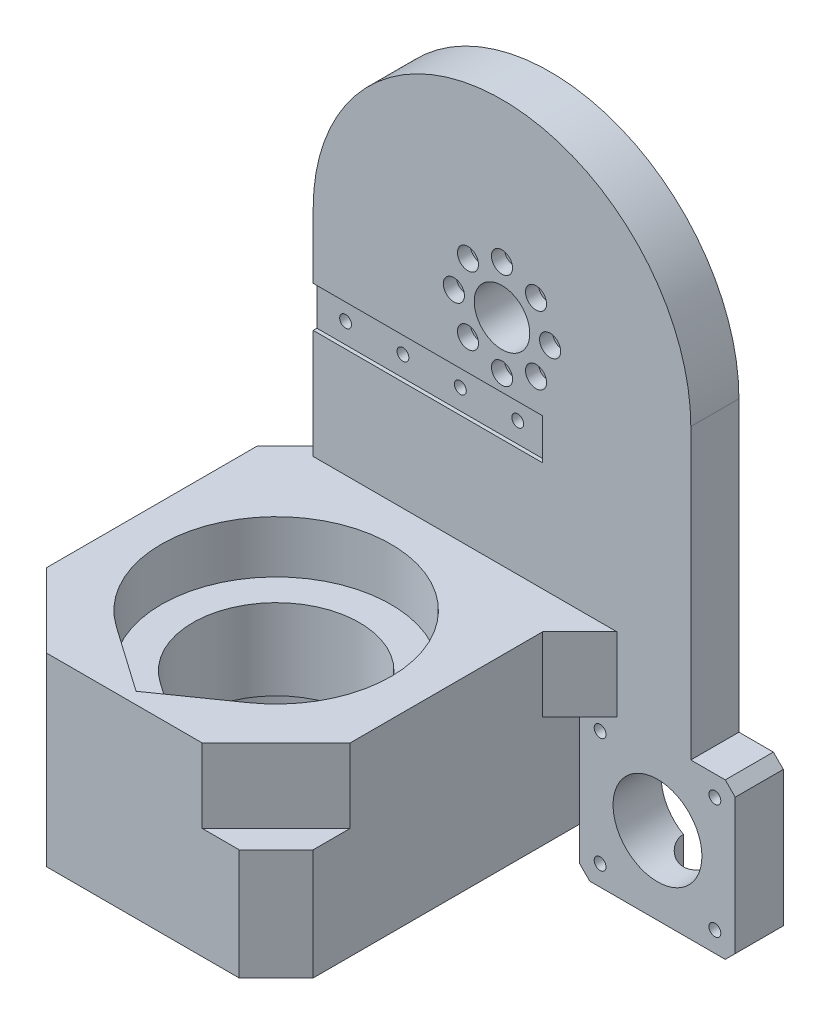
from build123d import *

# Parameters (mm, degrees)
SKETCH1_R               = 12
SKETCH1_R_2             = 7.5
SKETCH1_R_3             = 1.6
BOSS_EXTRUDE2_DEPTH     = 13
SKETCH1_6_W             = 50
SKETCH1_6_H             = 82
BOSS_EXTRUDE3_DEPTH     = 82
SKETCH1_5_R             = 2.85
CUT_EXTRUDE2_DEPTH      = 3.5
CUT_EXTRUDE3_DEPTH      = 14.1
CUT_EXTRUDE4_START      = -50
CUT_EXTRUDE4_DEPTH      = 14.1
CUT_EXTRUDE5_DEPTH      = 110
CUT_EXTRUDE5_DEPTH_BACK = 63
SKETCH3_W               = 62
SKETCH3_H               = 11
CUT_EXTRUDE6_DEPTH      = 1
SKETCH3_3_R             = 1.6
CUT_EXTRUDE7_DEPTH      = 14
CUT_EXTRUDE8_START      = -13
SKETCH3_5_R             = 2.85
CUT_EXTRUDE8_DEPTH      = 3.5
CUT_EXTRUDE9_START      = -13
SKETCH1_7_R             = 2.85
CUT_EXTRUDE9_DEPTH      = 3.5
CUT_EXTRUDE10_DEPTH     = 12.5
BOSS_EXTRUDE4_DEPTH     = 50
CUT_EXTRUDE11_DEPTH     = 50.5
BOSS_EXTRUDE5_DEPTH     = 20
CUT_EXTRUDE12_DEPTH     = 20
CHAMFER6_SIZE           = 10


with BuildPart() as part:
    # Sketch1 → Boss-Extrude2 (new body)
    with BuildSketch(Plane(origin=(0, 0, 0), x_dir=(0, 1, 0), z_dir=(0, 0, 1))):
        with BuildLine():
            Line((-68, -41), (-77.30151519, -41))
            Line((-77.30151519, -41), (-80, -43.69848481))
            Line((-80, -43.69848481), (-80, -80.30151519))
            Line((-80, -80.30151519), (-77.30151519, -83))
            Line((-77.30151519, -83), (-40.69848481, -83))
            Line((-40.69848481, -83), (-38, -80.30151519))
            Line((-38, -80.30151519), (-38, -71))
            Line((-38, -71), (40, -71))
            ThreePointArc((40, -71), (91, -20), (40, 31))
            Line((40, 31), (-68, 31))
            Line((-68, 31), (-68, -41))
        make_face()
        with Locations((-59, -62)):
            Circle(SKETCH1_R, mode=Mode.SUBTRACT)
        with Locations((40, -20)):
            Circle(SKETCH1_R_2, mode=Mode.SUBTRACT)
        with Locations((40, -7)):
            Circle(SKETCH1_R_3, mode=Mode.SUBTRACT)
        with Locations((49.192388155, -10.807611845)):
            Circle(SKETCH1_R_3, mode=Mode.SUBTRACT)
        with Locations((53, -20)):
            Circle(SKETCH1_R_3, mode=Mode.SUBTRACT)
        with Locations((49.192388155, -29.192388155)):
            Circle(SKETCH1_R_3, mode=Mode.SUBTRACT)
        with Locations((40, -33)):
            Circle(SKETCH1_R_3, mode=Mode.SUBTRACT)
        with Locations((30.807611845, -29.192388155)):
            Circle(SKETCH1_R_3, mode=Mode.SUBTRACT)
        with Locations((27, -20)):
            Circle(SKETCH1_R_3, mode=Mode.SUBTRACT)
        with Locations((30.807611845, -10.807611845)):
            Circle(SKETCH1_R_3, mode=Mode.SUBTRACT)
        with Locations((-74.5, -46.5)):
            Circle(SKETCH1_R_3, mode=Mode.SUBTRACT)
        with Locations((-43.5, -46.5)):
            Circle(SKETCH1_R_3, mode=Mode.SUBTRACT)
        with Locations((-43.5, -77.5)):
            Circle(SKETCH1_R_3, mode=Mode.SUBTRACT)
        with Locations((-74.5, -77.5)):
            Circle(SKETCH1_R_3, mode=Mode.SUBTRACT)
    extrude(amount=-BOSS_EXTRUDE2_DEPTH)

    # Sketch1_6 → Boss-Extrude3 (add)
    with BuildSketch(Plane(origin=(0, 0, 0), x_dir=(0, 1, 0), z_dir=(0, 0, 1))):
        with Locations((-43, 0)):
            Rectangle(SKETCH1_6_W, SKETCH1_6_H)
    extrude(amount=BOSS_EXTRUDE3_DEPTH)

    # Sketch1_5 → Cut-Extrude2 (cut)
    with BuildSketch(Plane(origin=(0, 0, 0), x_dir=(0, 1, 0), z_dir=(0, 0, 1))):
        with Locations((40, -7)):
            Circle(SKETCH1_5_R)
        with Locations((49.192388155, -10.807611845)):
            Circle(SKETCH1_5_R)
        with Locations((53, -20)):
            Circle(SKETCH1_5_R)
        with Locations((49.192388155, -29.192388155)):
            Circle(SKETCH1_5_R)
        with Locations((40, -33)):
            Circle(SKETCH1_5_R)
        with Locations((30.807611845, -29.192388155)):
            Circle(SKETCH1_5_R)
        with Locations((27, -20)):
            Circle(SKETCH1_5_R)
        with Locations((30.807611845, -10.807611845)):
            Circle(SKETCH1_5_R)
    extrude(amount=-CUT_EXTRUDE2_DEPTH, mode=Mode.SUBTRACT)

    # Sketch2 → Cut-Extrude3 (cut)
    with BuildSketch(Plane(origin=(0, -18, 0), x_dir=(-1, 0, 0), z_dir=(0, 1, 0))):
        with BuildLine():
            Line((-17.780869527, 66.393713373), (0, 78.844012252))
            Line((0, 78.844012252), (17.780869527, 66.393713373))
            ThreePointArc((17.780869527, 66.393713373), (0, 10), (-17.780869527, 66.393713373))
        make_face()
    extrude(amount=-CUT_EXTRUDE3_DEPTH, mode=Mode.SUBTRACT)

    # Sketch2_3 → Cut-Extrude4 (cut)
    with BuildSketch(Plane(origin=(0, -18, 0), x_dir=(-1, 0, 0), z_dir=(0, 1, 0)).offset(CUT_EXTRUDE4_START)):
        with BuildLine():
            Line((-17.780869527, 66.393713373), (0, 78.844012252))
            Line((0, 78.844012252), (17.780869527, 66.393713373))
            ThreePointArc((17.780869527, 66.393713373), (0, 10), (-17.780869527, 66.393713373))
        make_face()
        with BuildLine():
            Line((-12.905469818, 59.430920997), (0, 68.467428247))
            Line((0, 68.467428247), (12.905469818, 59.430920997))
            ThreePointArc((12.905469818, 59.430920997), (0, 18.5), (-12.905469818, 59.430920997))
        make_face(mode=Mode.SUBTRACT)
    extrude(amount=CUT_EXTRUDE4_DEPTH, mode=Mode.SUBTRACT)

    # Sketch2_4 → Cut-Extrude5 (cut, two sides)
    with BuildSketch(Plane(origin=(0, -18, 0), x_dir=(-1, 0, 0), z_dir=(0, 1, 0))) as cut_extrude5_sk:
        with BuildLine():
            Line((-12.905469818, 59.430920997), (0, 68.467428247))
            Line((0, 68.467428247), (12.905469818, 59.430920997))
            ThreePointArc((12.905469818, 59.430920997), (0, 18.5), (-12.905469818, 59.430920997))
        make_face()
    extrude(amount=CUT_EXTRUDE5_DEPTH, mode=Mode.SUBTRACT)
    extrude(cut_extrude5_sk.sketch, amount=-CUT_EXTRUDE5_DEPTH_BACK, mode=Mode.SUBTRACT)

    # Sketch3 → Cut-Extrude6 (cut)
    with BuildSketch(Plane.XY):
        with Locations((0, 17)):
            Rectangle(SKETCH3_W, SKETCH3_H)
    extrude(amount=-CUT_EXTRUDE6_DEPTH, mode=Mode.SUBTRACT)

    # Sketch3_3 → Cut-Extrude7 (cut, through all)
    with BuildSketch(Plane.XY):
        with Locations((-23.25, 17)):
            Circle(SKETCH3_3_R)
        with Locations((-7.75, 17)):
            Circle(SKETCH3_3_R)
        with Locations((7.75, 17)):
            Circle(SKETCH3_3_R)
        with Locations((23.25, 17)):
            Circle(SKETCH3_3_R)
    extrude(amount=-CUT_EXTRUDE7_DEPTH, mode=Mode.SUBTRACT)

    # Sketch3_5 → Cut-Extrude8 (cut)
    with BuildSketch(Plane.XY.offset(CUT_EXTRUDE8_START)):
        with Locations((-23.25, 17)):
            Circle(SKETCH3_5_R)
        with Locations((-7.75, 17)):
            Circle(SKETCH3_5_R)
        with Locations((7.75, 17)):
            Circle(SKETCH3_5_R)
        with Locations((23.25, 17)):
            Circle(SKETCH3_5_R)
    extrude(amount=CUT_EXTRUDE8_DEPTH, mode=Mode.SUBTRACT)

    # Sketch1_7 → Cut-Extrude9 (cut)
    with BuildSketch(Plane(origin=(0, 0, 0), x_dir=(0, 1, 0), z_dir=(0, 0, 1)).offset(CUT_EXTRUDE9_START)):
        with Locations((-74.5, -46.5)):
            Circle(SKETCH1_7_R)
        with Locations((-43.5, -46.5)):
            Circle(SKETCH1_7_R)
        with Locations((-43.5, -77.5)):
            Circle(SKETCH1_7_R)
        with Locations((-74.5, -77.5)):
            Circle(SKETCH1_7_R)
    extrude(amount=CUT_EXTRUDE9_DEPTH, mode=Mode.SUBTRACT)

    # Sketch4 → Cut-Extrude10 (cut)
    with BuildSketch(Plane.XZ.offset(80)):
        with BuildLine():
            Line((56, -13), (68, -13))
            ThreePointArc((68, -13), (62, -7), (56, -13))
        make_face()
    extrude(amount=-CUT_EXTRUDE10_DEPTH, mode=Mode.SUBTRACT)

    # Sketch5 → Boss-Extrude4 (add)
    with BuildSketch(Plane(origin=(0, -18, 0), x_dir=(-1, 0, 0), z_dir=(0, 1, 0))):
        Polygon((36, 0), (31, 0), (31, -5), align=None)
    extrude(amount=-BOSS_EXTRUDE4_DEPTH)

    # Sketch5_3 → Cut-Extrude11 (cut)
    with BuildSketch(Plane(origin=(0, -18, 0), x_dir=(-1, 0, 0), z_dir=(0, 1, 0))):
        Polygon((21, 82), (41, 62), (41, 82), align=None)
        Polygon((41, 5), (36, 0), (41, 0), align=None)
    extrude(amount=-CUT_EXTRUDE11_DEPTH, mode=Mode.SUBTRACT)

    # Sketch5_4 → Boss-Extrude5 (add)
    with BuildSketch(Plane(origin=(0, -18, 0), x_dir=(-1, 0, 0), z_dir=(0, 1, 0))):
        Polygon((-51, 0), (-41, 10), (-41, 0), align=None)
    extrude(amount=-BOSS_EXTRUDE5_DEPTH)

    # Sketch5_5 → Cut-Extrude12 (cut)
    with BuildSketch(Plane(origin=(0, -18, 0), x_dir=(-1, 0, 0), z_dir=(0, 1, 0))):
        Polygon((-41, 62), (-21, 82), (-41, 82), align=None)
    extrude(amount=-CUT_EXTRUDE12_DEPTH, mode=Mode.SUBTRACT)

    # Chamfer6
    chamfer6_edges = [part.edges().sort_by_distance(p)[0] for p in [
        (41, -53, 82),
    ]]
    chamfer(chamfer6_edges, length=CHAMFER6_SIZE)


solid = part.part
